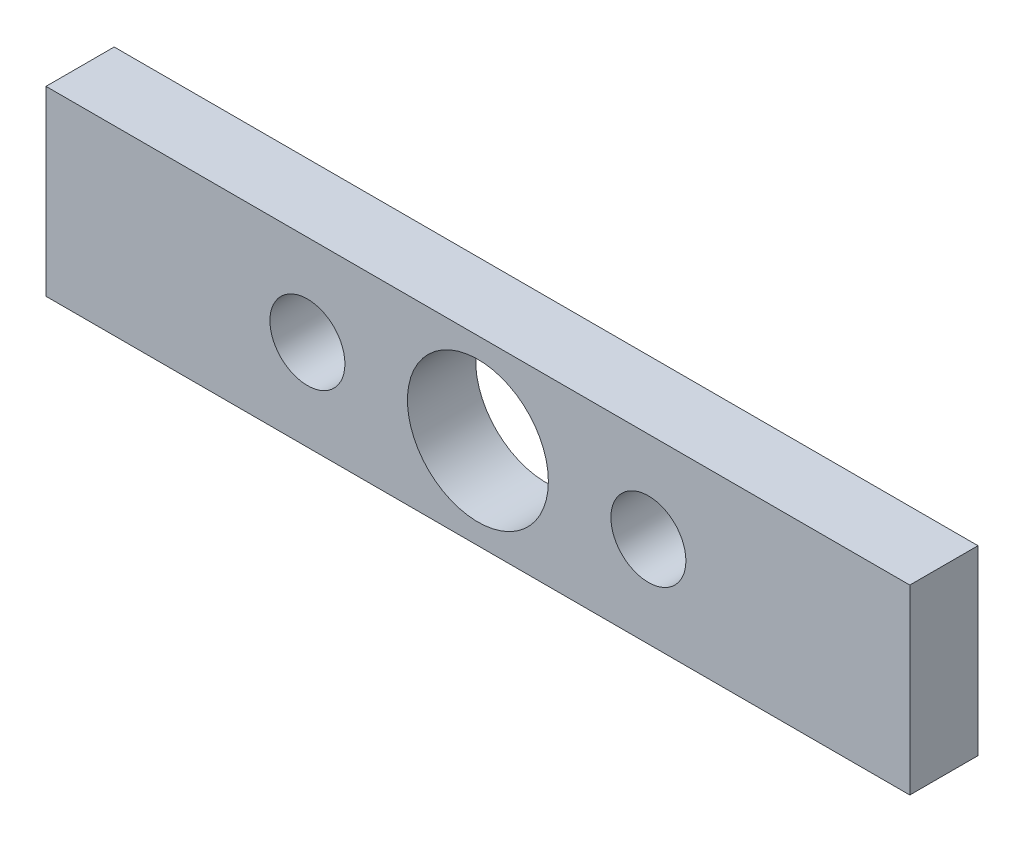
from build123d import *

# Parameters (mm, degrees)
SKETCH1_W           = 38
SKETCH1_H           = 8
BOSS_EXTRUDE1_DEPTH = 3
SKETCH2_R           = 3.1
SKETCH2_R_2         = 1.65
CUT_EXTRUDE1_DEPTH  = 4


with BuildPart() as part:
    # Sketch1 → Boss-Extrude1 (new body)
    with BuildSketch(Plane.XY):
        with Locations((0, 4)):
            Rectangle(SKETCH1_W, SKETCH1_H)
    extrude(amount=BOSS_EXTRUDE1_DEPTH)

    # Sketch2 → Cut-Extrude1 (cut, through all)
    with BuildSketch(Plane.XY.offset(3)):
        with Locations((0, 4)):
            Circle(SKETCH2_R)
        with Locations((-7.5, 4)):
            Circle(SKETCH2_R_2)
        with Locations((7.5, 4)):
            Circle(SKETCH2_R_2)
    extrude(amount=-CUT_EXTRUDE1_DEPTH, mode=Mode.SUBTRACT)


solid = part.part
